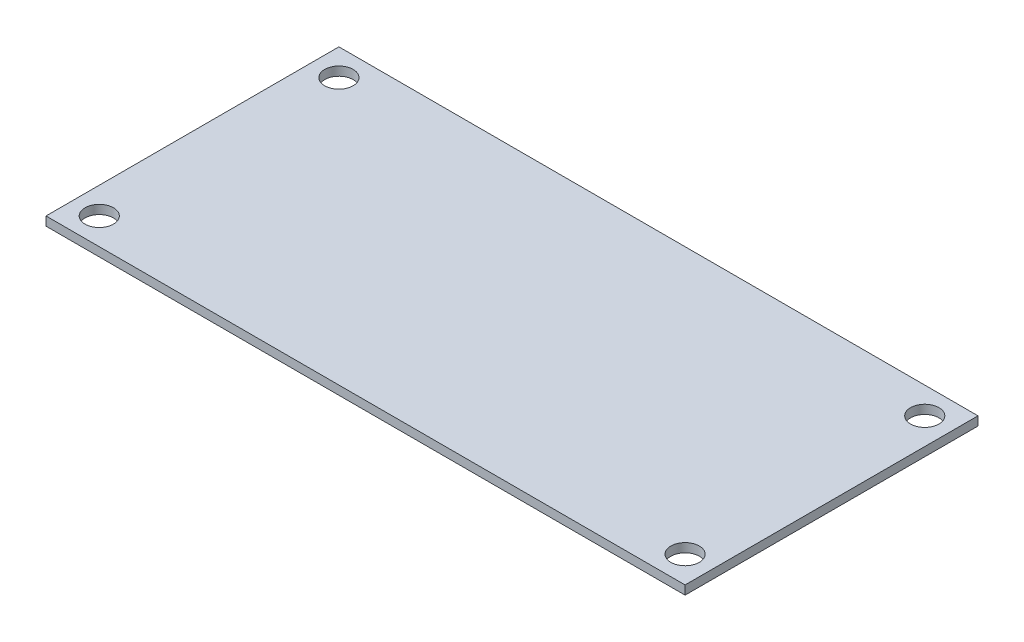
from build123d import *

# Parameters (mm, degrees)
SKETCH_2_W          = 72
SKETCH_2_H          = 33
EXTRUDE_1_DEPTH     = 1
SKETCH_3_R          = 1.6
CUT_EXTRUDE_1_DEPTH = 2


with BuildPart() as part:
    # ｽｹｯﾁ2 → ﾎﾞｽ - 押し出し1 (new body)
    with BuildSketch(Plane(origin=(0, 0, 0), x_dir=(1, 0, 0), z_dir=(0, 1, 0))):
        Rectangle(SKETCH_2_W, SKETCH_2_H)
    extrude(amount=EXTRUDE_1_DEPTH)

    # ｽｹｯﾁ3 → ｶｯﾄ - 押し出し1 (cut, through all)
    with BuildSketch(Plane(origin=(0, 1, 0), x_dir=(1, 0, 0), z_dir=(0, 1, 0))):
        with Locations((33, 13.5)):
            Circle(SKETCH_3_R)
        with Locations((33, -13.5)):
            Circle(SKETCH_3_R)
        with Locations((-33, -13.5)):
            Circle(SKETCH_3_R)
        with Locations((-33, 13.5)):
            Circle(SKETCH_3_R)
    extrude(amount=-CUT_EXTRUDE_1_DEPTH, mode=Mode.SUBTRACT)


solid = part.part
